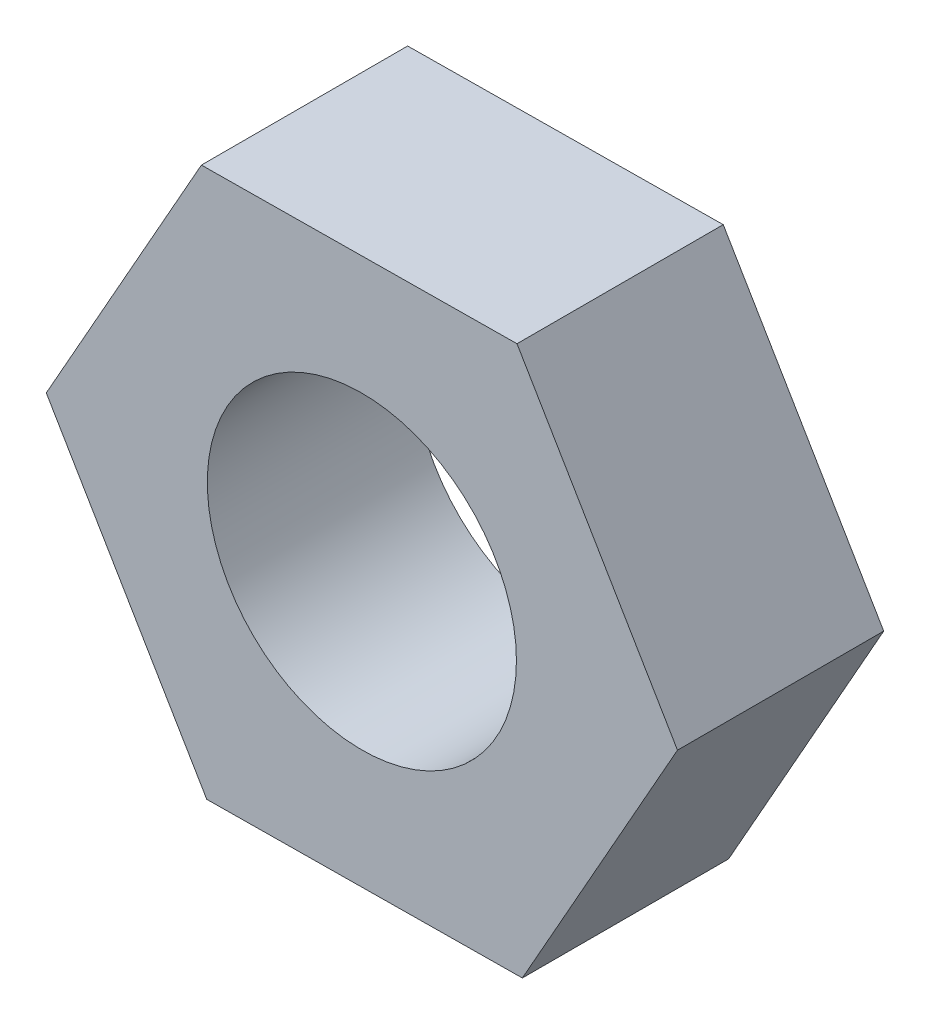
from build123d import *

# Parameters (mm, degrees)
DODANIE_WYCI_GNI_CIE1_DEPTH = 4.15
SZKIC2_R                    = 3.11
WYTNIJ_WYCI_GNI_CIE1_DEPTH  = 5.15


with BuildPart() as part:
    # Szkic1 → Dodanie-wyciągnięcie1 (new body)
    with BuildSketch(Plane.XY):
        Polygon((-3.229086971, 5.468668089), (-6.350548975, -0.062137304), (-3.121462004, -5.530805393), (3.229086971, -5.468668089), (6.350548975, 0.062137304), (3.121462004, 5.530805393), align=None)
    extrude(amount=DODANIE_WYCI_GNI_CIE1_DEPTH)

    # Szkic2 → Wytnij-wyciągnięcie1 (cut, through all)
    with BuildSketch(Plane.XY.offset(4.15)):
        Circle(SZKIC2_R)
    extrude(amount=-WYTNIJ_WYCI_GNI_CIE1_DEPTH, mode=Mode.SUBTRACT)


solid = part.part
